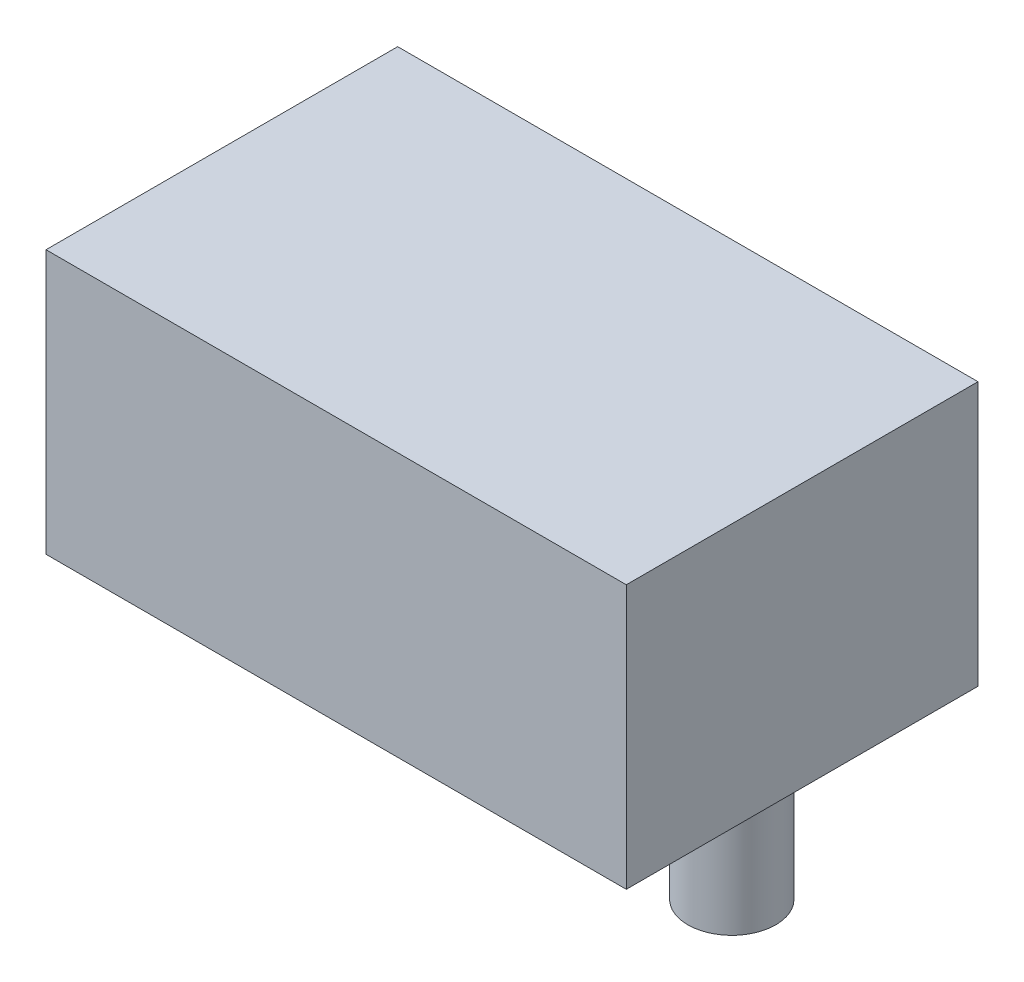
from build123d import *

# Parameters (mm, degrees)
SKETCH1_W           = 41.91
SKETCH1_H           = 25.4
BOSS_EXTRUDE1_DEPTH = 19.05
SKETCH1_4_R         = 6.2865
CUT_EXTRUDE1_DEPTH  = 9.525
SKETCH1_5_R         = 3.175
BOSS_EXTRUDE2_DEPTH = 9.525


with BuildPart() as part:
    # Sketch1 → Boss-Extrude1 (new body)
    with BuildSketch(Plane(origin=(0, 0, 0), x_dir=(1, 0, 0), z_dir=(0, 1, 0))):
        Rectangle(SKETCH1_W, SKETCH1_H)
    extrude(amount=BOSS_EXTRUDE1_DEPTH)

    # Sketch1_4 → Cut-Extrude1 (cut)
    with BuildSketch(Plane(origin=(0, 0, 0), x_dir=(1, 0, 0), z_dir=(0, 1, 0))):
        Circle(SKETCH1_4_R)
    extrude(amount=CUT_EXTRUDE1_DEPTH, mode=Mode.SUBTRACT)

    # Sketch1_5 → Boss-Extrude2 (add)
    with BuildSketch(Plane(origin=(0, 0, 0), x_dir=(1, 0, 0), z_dir=(0, 1, 0))):
        with Locations((-15.875, 0)):
            Circle(SKETCH1_5_R)
        with Locations((15.875, 0)):
            Circle(SKETCH1_5_R)
    extrude(amount=-BOSS_EXTRUDE2_DEPTH)


solid = part.part
